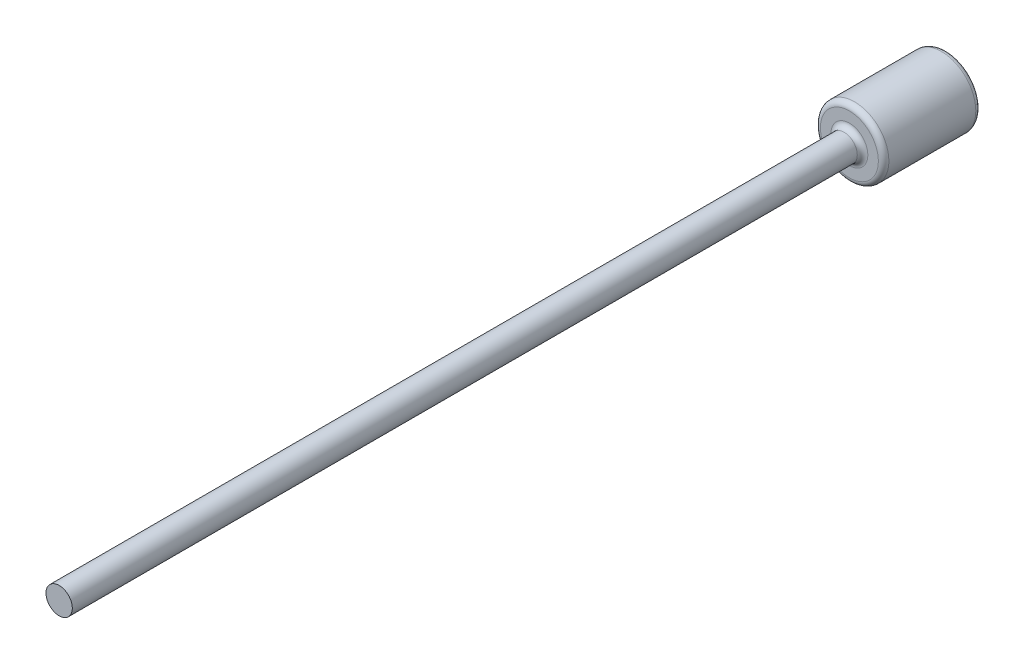
from build123d import *

# Parameters (mm, degrees)
SKETCH1_R           = 13
BOSS_EXTRUDE1_DEPTH = 37
SKETCH2_R           = 5
BOSS_EXTRUDE2_DEPTH = 280
SKETCH3_R           = 5
BOSS_EXTRUDE3_DEPTH = 20
FILLET1_R           = 2


with BuildPart() as part:
    # Sketch1 → Boss-Extrude1 (new body)
    with BuildSketch(Plane.XY):
        Circle(SKETCH1_R)
    extrude(amount=-BOSS_EXTRUDE1_DEPTH)

    # Sketch2 → Boss-Extrude2 (add)
    with BuildSketch(Plane.XY):
        Circle(SKETCH2_R)
    extrude(amount=BOSS_EXTRUDE2_DEPTH)

    # Sketch3 → Boss-Extrude3 (add)
    with BuildSketch(Plane.XY.offset(280)):
        Circle(SKETCH3_R)
    extrude(amount=BOSS_EXTRUDE3_DEPTH)

    # Fillet1
    fillet1_edges = [part.edges().sort_by_distance(p)[0] for p in [
        (-13, 0, 0),
        (-13, 0, -37),
        (-5, 0, 0),
    ]]
    fillet(fillet1_edges, radius=FILLET1_R)


solid = part.part
